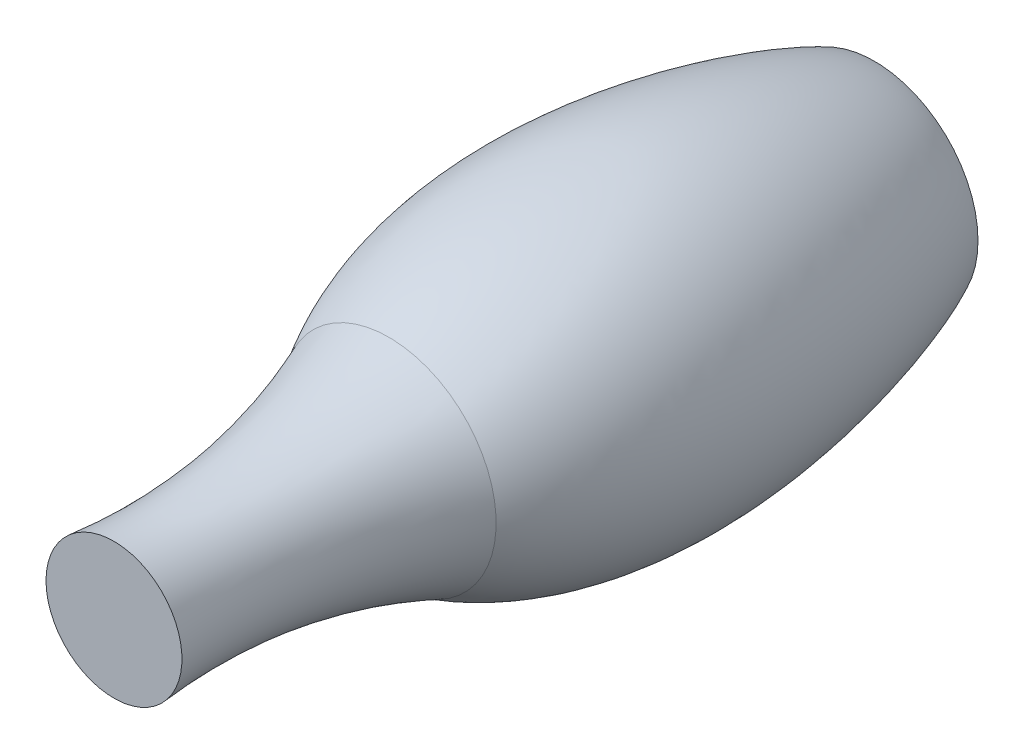
from build123d import *

# Parameters (mm, degrees)
SKETCH5_R          = 1250
CUT_EXTRUDE2_DEPTH = 250
SKETCH8_R          = 300
CUT_EXTRUDE5_DEPTH = 250


with BuildPart() as part:
    # Sketch2 → Revolve4 (revolve)
    with BuildSketch(Plane(origin=(0, 0, 0), x_dir=(1, 0, 0), z_dir=(0, 1, 0))):
        with BuildLine():
            Line((983.947861403, -11007.958646251), (0, -11007.958646251))
            Line((0, -11007.958646251), (0, 0))
            Line((0, 0), (1500, 0))
            add(Edge.make_bspline(
                [(1500, 0), (1901.182531153, -776.853983433), (3061.461672261, -4517.414953739), (1552.785010708, -7028.326321897)],
                knots=[0, 0, 0, 0, 1, 1, 1, 1], degree=3))
            add(Edge.make_bspline(
                [(983.947861403, -11007.958646251), (778.02463544, -8933.856534366), (1552.785010708, -7028.326321897)],
                knots=[0, 0, 0, 1, 1, 1], degree=2))
        make_face()
    revolve(axis=Axis((0, 0, 0), (0, 0, 1)))

    # Sketch5 → Cut-Extrude2 (cut)
    with BuildSketch(Plane(origin=(0, 0, 0), x_dir=(-1, 0, 0), z_dir=(0, 0, -1))):
        Circle(SKETCH5_R)
    extrude(amount=-CUT_EXTRUDE2_DEPTH, mode=Mode.SUBTRACT)

    # Sketch8 → Cut-Extrude5 (cut)
    with BuildSketch(Plane(origin=(0, 0, 250), x_dir=(-1, 0, 0), z_dir=(0, 0, -1))):
        with Locations((800.554534759, 0)):
            Circle(SKETCH8_R)
        with Locations((400.27726738, -693.300564216)):
            Circle(SKETCH8_R)
        with Locations((-400.27726738, -693.300564216)):
            Circle(SKETCH8_R)
        with Locations((-800.554534759, 0)):
            Circle(SKETCH8_R)
        with Locations((-400.27726738, 693.300564216)):
            Circle(SKETCH8_R)
        with Locations((400.27726738, 693.300564216)):
            Circle(SKETCH8_R)
    extrude(amount=-CUT_EXTRUDE5_DEPTH, mode=Mode.SUBTRACT)


solid = part.part
